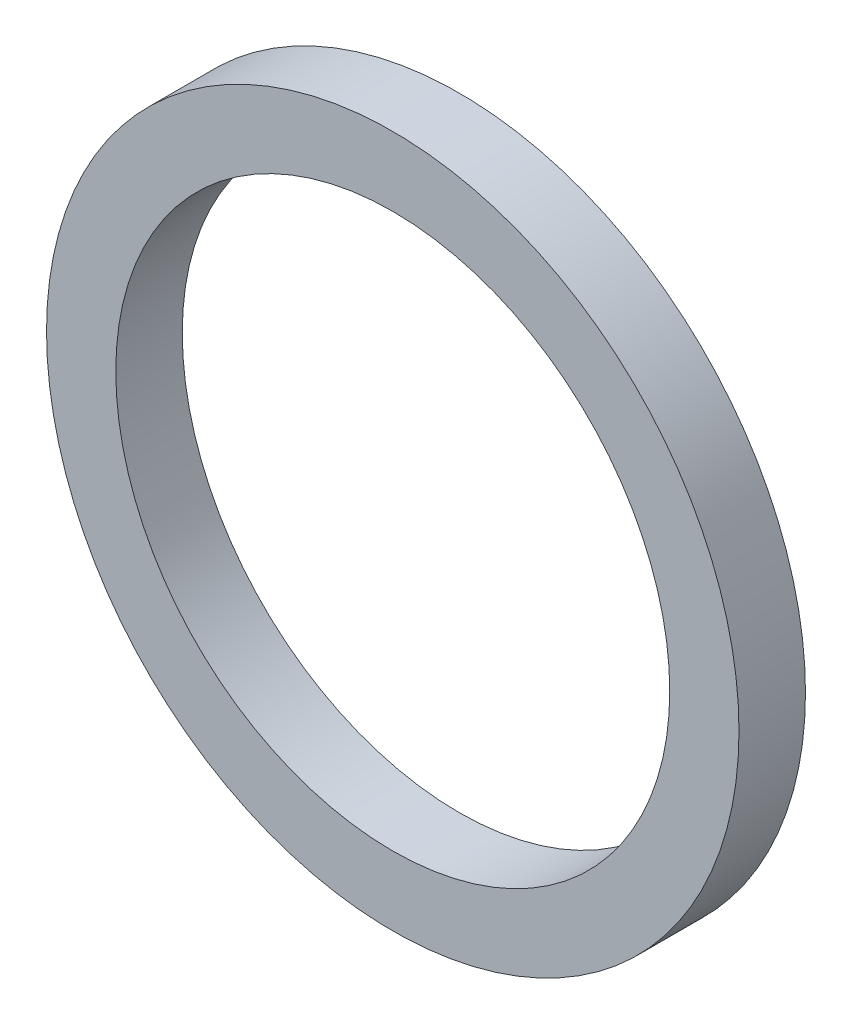
from build123d import *

# Parameters (mm, degrees)
SKETCH1_R           = 3.96875
SKETCH1_R_2         = 3.175
BOSS_EXTRUDE1_DEPTH = 0.381


with BuildPart() as part:
    # Sketch1 → Boss-Extrude1 (new body, symmetric)
    with BuildSketch(Plane.XY):
        Circle(SKETCH1_R)
        Circle(SKETCH1_R_2, mode=Mode.SUBTRACT)
    extrude(amount=BOSS_EXTRUDE1_DEPTH, both=True)


solid = part.part
